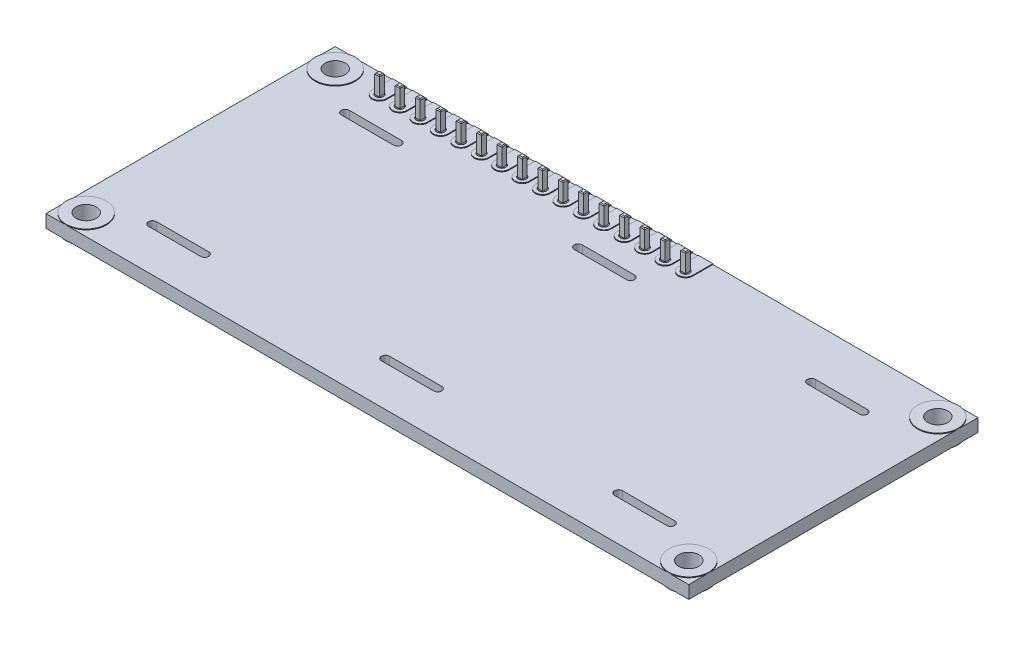
from build123d import *

# Parameters (mm, degrees)
SKETCH1_W                  = 80
SKETCH1_H                  = 36
SKETCH1_R                  = 1.25
SKETCH1_R_2                = 0.5
BOSS_EXTRUDE1_DEPTH        = 1.6
SKETCH2_R                  = 0.5
BOSS_EXTRUDE2_DEPTH        = 0.1
LPATTERN1_COUNT            = 16
LPATTERN1_PITCH            = 2.54
SKETCH3_R                  = 2.5
SKETCH3_R_2                = 1.25
BOSS_EXTRUDE3_DEPTH        = 0.1
SKETCH4_R                  = 2.5
SKETCH4_R_2                = 1.25
BOSS_EXTRUDE4_DEPTH        = 0.1
SKETCH5_W                  = 0.6
SKETCH5_H                  = 0.6
BOSS_EXTRUDE5_DEPTH        = 2.2
SKETCH6_W                  = 0.6
SKETCH6_H                  = 0.6
BOSS_EXTRUDE6_DEPTH        = 0.1
BOSS_EXTRUDE6_TAPER        = 45
SKETCH7_W                  = 0.6
SKETCH7_H                  = 0.6
BOSS_EXTRUDE7_DEPTH        = 0.1
BOSS_EXTRUDE7_TAPER        = 45
LPATTERN2_COUNT            = 16
LPATTERN2_PITCH            = 2.54
SKETCH8_W                  = 40.5
SKETCH8_H                  = 2.5
BOSS_EXTRUDE8_DEPTH        = 9
SKETCH9_W                  = 1
SKETCH9_H                  = 1
CUT_EXTRUDE1_DEPTH         = 8
CHAMFER1_SIZE              = 0.375
LPATTERN3_COUNT            = 16
LPATTERN3_PITCH            = 2.5
CHAMFER1_OF_LPATTERN3_SIZE = 0.375


with BuildPart() as part:
    # Sketch1 → Boss-Extrude1 (new body)
    with BuildSketch(Plane(origin=(0, 0, 0), x_dir=(1, 0, 0), z_dir=(0, 1, 0))):
        Rectangle(SKETCH1_W, SKETCH1_H)
        with Locations((-37.5, 15.5)):
            Circle(SKETCH1_R, mode=Mode.SUBTRACT)
        with Locations((-37.5, -15.5)):
            Circle(SKETCH1_R, mode=Mode.SUBTRACT)
        with Locations((37.5, 15.5)):
            Circle(SKETCH1_R, mode=Mode.SUBTRACT)
        with Locations((37.5, -15.5)):
            Circle(SKETCH1_R, mode=Mode.SUBTRACT)
        with Locations((-32, 15.5)):
            Circle(SKETCH1_R_2, mode=Mode.SUBTRACT)
        with Locations((-29.46, 15.5)):
            Circle(SKETCH1_R_2, mode=Mode.SUBTRACT)
        with Locations((-26.92, 15.5)):
            Circle(SKETCH1_R_2, mode=Mode.SUBTRACT)
        with Locations((-24.38, 15.5)):
            Circle(SKETCH1_R_2, mode=Mode.SUBTRACT)
        with Locations((-21.84, 15.5)):
            Circle(SKETCH1_R_2, mode=Mode.SUBTRACT)
        with Locations((-19.3, 15.5)):
            Circle(SKETCH1_R_2, mode=Mode.SUBTRACT)
        with Locations((-16.76, 15.5)):
            Circle(SKETCH1_R_2, mode=Mode.SUBTRACT)
        with Locations((-14.22, 15.5)):
            Circle(SKETCH1_R_2, mode=Mode.SUBTRACT)
        with Locations((-11.68, 15.5)):
            Circle(SKETCH1_R_2, mode=Mode.SUBTRACT)
        with Locations((-9.14, 15.5)):
            Circle(SKETCH1_R_2, mode=Mode.SUBTRACT)
        with Locations((-6.6, 15.5)):
            Circle(SKETCH1_R_2, mode=Mode.SUBTRACT)
        with Locations((-4.06, 15.5)):
            Circle(SKETCH1_R_2, mode=Mode.SUBTRACT)
        with Locations((-1.52, 15.5)):
            Circle(SKETCH1_R_2, mode=Mode.SUBTRACT)
        with Locations((1.02, 15.5)):
            Circle(SKETCH1_R_2, mode=Mode.SUBTRACT)
        with Locations((3.56, 15.5)):
            Circle(SKETCH1_R_2, mode=Mode.SUBTRACT)
        with Locations((6.1, 15.5)):
            Circle(SKETCH1_R_2, mode=Mode.SUBTRACT)
        with BuildLine():
            Line((-3.25, -12), (3.25, -12))
            ThreePointArc((3.25, -12), (3.75, -12.5), (3.25, -13))
            Line((3.25, -13), (-3.25, -13))
            ThreePointArc((-3.25, -13), (-3.75, -12.5), (-3.25, -12))
        make_face(mode=Mode.SUBTRACT)
        with BuildLine():
            Line((25.75, -12), (32.25, -12))
            ThreePointArc((32.25, -12), (32.75, -12.5), (32.25, -13))
            Line((32.25, -13), (25.75, -13))
            ThreePointArc((25.75, -13), (25.25, -12.5), (25.75, -12))
        make_face(mode=Mode.SUBTRACT)
        with BuildLine():
            Line((25.75, 12), (32.25, 12))
            ThreePointArc((32.25, 12), (32.75, 11.5), (32.25, 11))
            Line((32.25, 11), (25.75, 11))
            ThreePointArc((25.75, 11), (25.25, 11.5), (25.75, 12))
        make_face(mode=Mode.SUBTRACT)
        with BuildLine():
            Line((-3.25, 12), (3.25, 12))
            ThreePointArc((3.25, 12), (3.75, 11.5), (3.25, 11))
            Line((3.25, 11), (-3.25, 11))
            ThreePointArc((-3.25, 11), (-3.75, 11.5), (-3.25, 12))
        make_face(mode=Mode.SUBTRACT)
        with BuildLine():
            Line((-32.25, -12), (-25.75, -12))
            ThreePointArc((-25.75, -12), (-25.25, -12.5), (-25.75, -13))
            Line((-25.75, -13), (-32.25, -13))
            ThreePointArc((-32.25, -13), (-32.75, -12.5), (-32.25, -12))
        make_face(mode=Mode.SUBTRACT)
        with BuildLine():
            Line((-32.25, 12), (-25.75, 12))
            ThreePointArc((-25.75, 12), (-25.25, 11.5), (-25.75, 11))
            Line((-25.75, 11), (-32.25, 11))
            ThreePointArc((-32.25, 11), (-32.75, 11.5), (-32.25, 12))
        make_face(mode=Mode.SUBTRACT)
    extrude(amount=-BOSS_EXTRUDE1_DEPTH)

    # Sketch2 → Boss-Extrude2 (add)
    with BuildSketch(Plane(origin=(0, 0, 0), x_dir=(1, 0, 0), z_dir=(0, 1, 0))):
        with BuildLine():
            Line((-32.9, 15.5), (-32.9, 18))
            Line((-32.9, 18), (-31.1, 18))
            Line((-31.1, 18), (-31.1, 15.5))
            ThreePointArc((-31.1, 15.5), (-32, 14.6), (-32.9, 15.5))
        make_face()
        with Locations((-32, 15.5)):
            Circle(SKETCH2_R, mode=Mode.SUBTRACT)
    boss_extrude2 = extrude(amount=BOSS_EXTRUDE2_DEPTH)

    # LPattern1: Boss-Extrude2 ×16
    with Locations(*[(i * LPATTERN1_PITCH, 0, 0) for i in range(1, LPATTERN1_COUNT)]):
        add(boss_extrude2)

    # Sketch3 → Boss-Extrude3 (add)
    with BuildSketch(Plane(origin=(0, 0, 0), x_dir=(1, 0, 0), z_dir=(0, 1, 0))):
        with Locations((-37.5, 15.5)):
            Circle(SKETCH3_R)
        with Locations((-37.5, 15.5)):
            Circle(SKETCH3_R_2, mode=Mode.SUBTRACT)
        with Locations((-37.5, -15.5)):
            Circle(SKETCH3_R)
        with Locations((-37.5, -15.5)):
            Circle(SKETCH3_R_2, mode=Mode.SUBTRACT)
        with Locations((37.5, -15.5)):
            Circle(SKETCH3_R)
        with Locations((37.5, -15.5)):
            Circle(SKETCH3_R_2, mode=Mode.SUBTRACT)
        with Locations((37.5, 15.5)):
            Circle(SKETCH3_R)
        with Locations((37.5, 15.5)):
            Circle(SKETCH3_R_2, mode=Mode.SUBTRACT)
    extrude(amount=BOSS_EXTRUDE3_DEPTH)

    # Sketch4 → Boss-Extrude4 (add)
    with BuildSketch(Plane.XZ.offset(1.6)):
        with Locations((37.5, -15.5)):
            Circle(SKETCH4_R)
        with Locations((37.5, -15.5)):
            Circle(SKETCH4_R_2, mode=Mode.SUBTRACT)
        with Locations((37.5, 15.5)):
            Circle(SKETCH4_R)
        with Locations((37.5, 15.5)):
            Circle(SKETCH4_R_2, mode=Mode.SUBTRACT)
        with Locations((-37.5, 15.5)):
            Circle(SKETCH4_R)
        with Locations((-37.5, 15.5)):
            Circle(SKETCH4_R_2, mode=Mode.SUBTRACT)
        with Locations((-37.5, -15.5)):
            Circle(SKETCH4_R)
        with Locations((-37.5, -15.5)):
            Circle(SKETCH4_R_2, mode=Mode.SUBTRACT)
    extrude(amount=BOSS_EXTRUDE4_DEPTH)

    # Sketch8 → Boss-Extrude8 (add)
    with BuildSketch(Plane.XZ.offset(1.6)):
        with Locations((-13, -15.5)):
            Rectangle(SKETCH8_W, SKETCH8_H)
    extrude(amount=BOSS_EXTRUDE8_DEPTH)

    # Sketch9 → Cut-Extrude1 (cut)
    with BuildSketch(Plane.XZ.offset(10.6)):
        with Locations((-31.75, -15.5)):
            Rectangle(SKETCH9_W, SKETCH9_H)
    cut_extrude1 = extrude(amount=-CUT_EXTRUDE1_DEPTH, mode=Mode.SUBTRACT)

    # Chamfer1
    chamfer1_edges = [part.edges().sort_by_distance(p)[0] for p in [
        (-31.25, -10.6, -15.5),
        (-31.75, -10.6, -15),
        (-32.25, -10.6, -15.5),
        (-31.75, -10.6, -16),
    ]]
    chamfer(chamfer1_edges, length=CHAMFER1_SIZE)

    # LPattern3: Cut-Extrude1 ×16
    with Locations(*[(i * LPATTERN3_PITCH, 0, 0) for i in range(1, LPATTERN3_COUNT)]):
        add(cut_extrude1, mode=Mode.SUBTRACT)

    # Chamfer1 of LPattern3
    chamfer1_of_lpattern3_edges = [part.edges().sort_by_distance(p)[0] for p in [
        (-28.75, -10.6, -15.5),
        (-29.25, -10.6, -15),
        (-29.75, -10.6, -15.5),
        (-29.25, -10.6, -16),
        (-26.25, -10.6, -15.5),
        (-26.75, -10.6, -15),
        (-27.25, -10.6, -15.5),
        (-26.75, -10.6, -16),
        (-23.75, -10.6, -15.5),
        (-24.25, -10.6, -15),
        (-24.75, -10.6, -15.5),
        (-24.25, -10.6, -16),
        (-21.25, -10.6, -15.5),
        (-21.75, -10.6, -15),
        (-22.25, -10.6, -15.5),
        (-21.75, -10.6, -16),
        (-18.75, -10.6, -15.5),
        (-19.25, -10.6, -15),
        (-19.75, -10.6, -15.5),
        (-19.25, -10.6, -16),
        (-16.25, -10.6, -15.5),
        (-16.75, -10.6, -15),
        (-17.25, -10.6, -15.5),
        (-16.75, -10.6, -16),
        (-13.75, -10.6, -15.5),
        (-14.25, -10.6, -15),
        (-14.75, -10.6, -15.5),
        (-14.25, -10.6, -16),
        (-11.25, -10.6, -15.5),
        (-11.75, -10.6, -15),
        (-12.25, -10.6, -15.5),
        (-11.75, -10.6, -16),
        (-8.75, -10.6, -15.5),
        (-9.25, -10.6, -15),
        (-9.75, -10.6, -15.5),
        (-9.25, -10.6, -16),
        (-6.25, -10.6, -15.5),
        (-6.75, -10.6, -15),
        (-7.25, -10.6, -15.5),
        (-6.75, -10.6, -16),
        (-3.75, -10.6, -15.5),
        (-4.25, -10.6, -15),
        (-4.75, -10.6, -15.5),
        (-4.25, -10.6, -16),
        (-1.25, -10.6, -15.5),
        (-1.75, -10.6, -15),
        (-2.25, -10.6, -15.5),
        (-1.75, -10.6, -16),
        (1.25, -10.6, -15.5),
        (0.75, -10.6, -15),
        (0.25, -10.6, -15.5),
        (0.75, -10.6, -16),
        (3.75, -10.6, -15.5),
        (3.25, -10.6, -15),
        (2.75, -10.6, -15.5),
        (3.25, -10.6, -16),
        (6.25, -10.6, -15.5),
        (5.75, -10.6, -15),
        (5.25, -10.6, -15.5),
        (5.75, -10.6, -16),
    ]]
    chamfer(chamfer1_of_lpattern3_edges, length=CHAMFER1_OF_LPATTERN3_SIZE)


with BuildPart() as body_2:
    # Sketch5 → Boss-Extrude5 (new body)
    with BuildSketch(Plane(origin=(0, 0.1, 0), x_dir=(1, 0, 0), z_dir=(0, 1, 0))):
        with Locations((-32, 15.5)):
            Rectangle(SKETCH5_W, SKETCH5_H)
    boss_extrude5 = extrude(amount=BOSS_EXTRUDE5_DEPTH)

    # Sketch6 → Boss-Extrude6 (add)
    with BuildSketch(Plane(origin=(0, 2.3, 0), x_dir=(1, 0, 0), z_dir=(0, 1, 0))):
        with Locations((-32, 15.5)):
            Rectangle(SKETCH6_W, SKETCH6_H)
    boss_extrude6 = extrude(amount=BOSS_EXTRUDE6_DEPTH, taper=BOSS_EXTRUDE6_TAPER)

    # Sketch7 → Boss-Extrude7 (add)
    with BuildSketch(Plane.XZ.offset(-0.1)):
        with Locations((-32, -15.5)):
            Rectangle(SKETCH7_W, SKETCH7_H)
    boss_extrude7 = extrude(amount=BOSS_EXTRUDE7_DEPTH, taper=BOSS_EXTRUDE7_TAPER)


with BuildPart() as lpattern2_1:
    # LPattern2: Boss-Extrude5, Boss-Extrude6, Boss-Extrude7 ×16
    with Locations(*[(i * LPATTERN2_PITCH, 0, 0) for i in range(1, LPATTERN2_COUNT)]):
        add(boss_extrude5)
        add(boss_extrude6)
        add(boss_extrude7)


solid = Compound([part.part, body_2.part, lpattern2_1.part])
